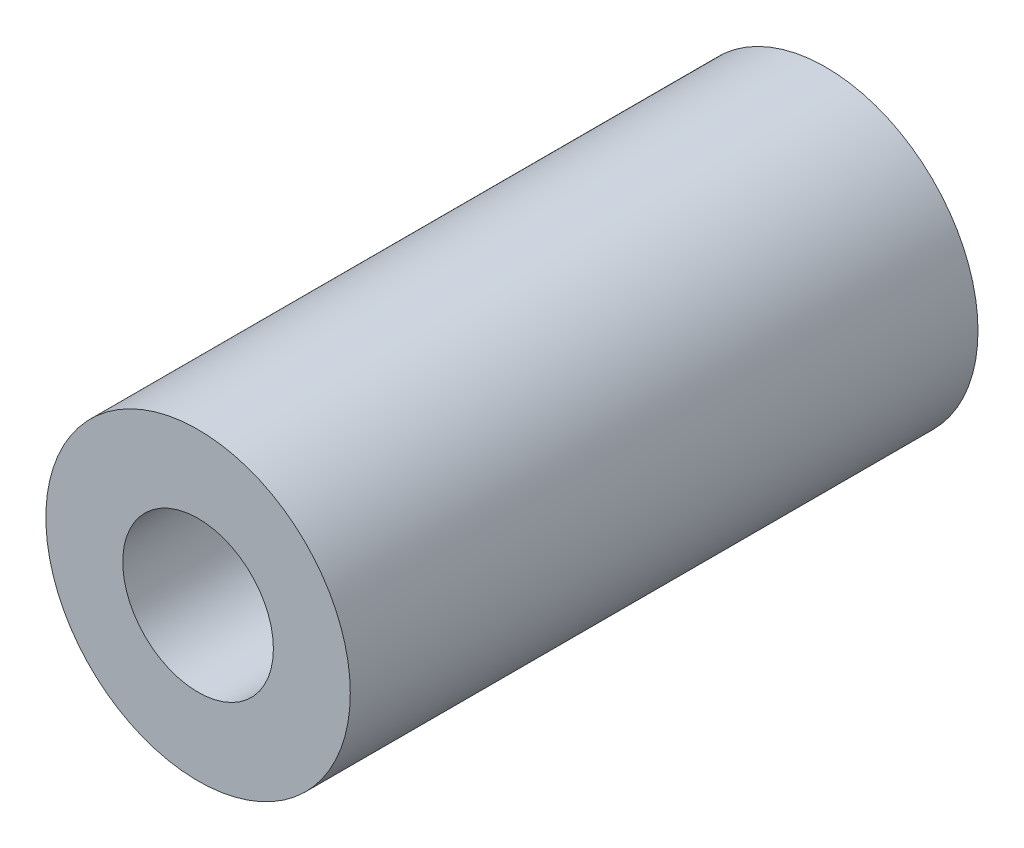
from build123d import *

# Parameters (mm, degrees)
SKETCH1_R           = 4.85
SKETCH1_R_2         = 2.4
BOSS_EXTRUDE1_DEPTH = 20


with BuildPart() as part:
    # Sketch1 → Boss-Extrude1 (new body)
    with BuildSketch(Plane.XY):
        Circle(SKETCH1_R)
        Circle(SKETCH1_R_2, mode=Mode.SUBTRACT)
    extrude(amount=BOSS_EXTRUDE1_DEPTH)


solid = part.part
